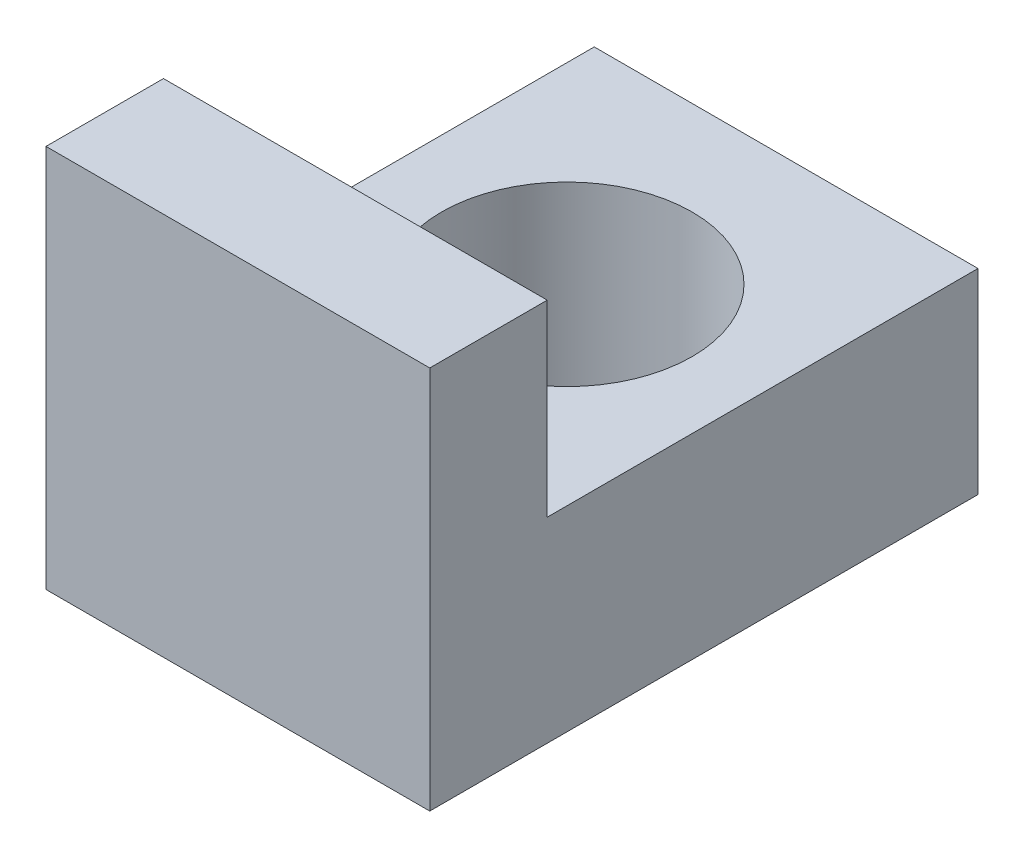
from build123d import *

# Parameters (mm, degrees)
BOSS_EXTRUDE1_DEPTH = 4.9
SKETCH2_R           = 1.6
CUT_EXTRUDE1_DEPTH  = 5.9


with BuildPart() as part:
    # Sketch1 → Boss-Extrude1 (new body)
    with BuildSketch(Plane(origin=(0, 0, 0), x_dir=(0, 0, -1), z_dir=(1, 0, 0))):
        Polygon((0, 0), (0, 4.9), (1.5, 4.9), (1.5, 2.5), (7, 2.5), (7, 0), align=None)
    extrude(amount=BOSS_EXTRUDE1_DEPTH)

    # Sketch2 → Cut-Extrude1 (cut, through all)
    with BuildSketch(Plane.XZ):
        with Locations((2.45, -4.2)):
            Circle(SKETCH2_R)
    extrude(amount=-CUT_EXTRUDE1_DEPTH, mode=Mode.SUBTRACT)


solid = part.part
